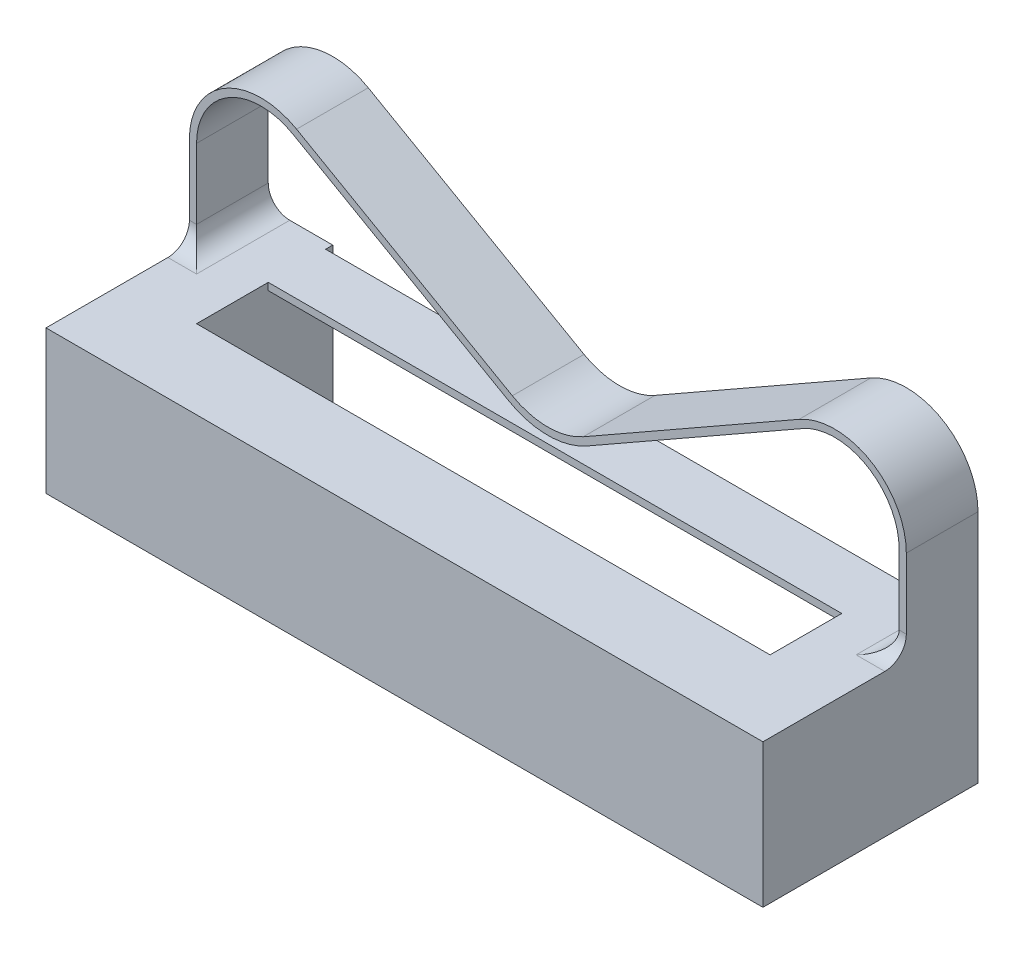
from build123d import *

# Parameters (mm, degrees)
SKIZZE1_W                         = 100
SKIZZE1_H                         = 20
AUFSATZ_LINEAR_AUSTRAGEN1_DEPTH   = 50
SKIZZE3_W                         = 80
SKIZZE3_H                         = 10
SCHNITT_LINEAR_AUSTRAGEN1_DEPTH   = 21
SKIZZE4_W                         = 80
SKIZZE4_H                         = 18
SCHNITT_LINEAR_AUSTRAGEN2_DEPTH   = 19
LINEAR_AUSTRAGEN_D_NN1_DEPTH      = 5
LINEAR_AUSTRAGEN_D_NN1_DEPTH_BACK = 5
SKIZZE5_W                         = 100
SKIZZE5_H                         = 20
SCHNITT_LINEAR_AUSTRAGEN3_DEPTH   = 20
VERRUNDUNG1_R                     = 3


with BuildPart() as part:
    # Skizze1 → Aufsatz-Linear austragen1 (new body)
    with BuildSketch(Plane.XY):
        with Locations((50, 10)):
            Rectangle(SKIZZE1_W, SKIZZE1_H)
    extrude(amount=AUFSATZ_LINEAR_AUSTRAGEN1_DEPTH)

    # Skizze3 → Schnitt-Linear austragen1 (cut, through all)
    with BuildSketch(Plane.XZ):
        with Locations((50, 34)):
            Rectangle(SKIZZE3_W, SKIZZE3_H)
        with Locations((50, 16)):
            Rectangle(SKIZZE3_W, SKIZZE3_H)
    extrude(amount=-SCHNITT_LINEAR_AUSTRAGEN1_DEPTH, mode=Mode.SUBTRACT)

    # Skizze4 → Schnitt-Linear austragen2 (cut)
    with BuildSketch(Plane.XZ):
        with Locations((50, 25)):
            Rectangle(SKIZZE4_W, SKIZZE4_H)
    extrude(amount=-SCHNITT_LINEAR_AUSTRAGEN2_DEPTH, mode=Mode.SUBTRACT)

    # Skizze2 → Linear-Austragen-Dünn1 (add, two sides)
    with BuildSketch(Plane.XY.offset(25)) as linear_austragen_d_nn1_sk:
        with BuildLine():
            Line((0, 20), (0, 32.789569947))
            ThreePointArc((0, 32.789569947), (4.976072473, 41.435965277), (14.95203044, 41.477342649))
            Line((14.95203044, 41.477342649), (45.04796956, 24.322657351))
            ThreePointArc((45.04796956, 24.322657351), (50, 23.010430053), (54.95203044, 24.322657351))
            Line((54.95203044, 24.322657351), (85.04796956, 41.477342649))
            ThreePointArc((85.04796956, 41.477342649), (95.023927527, 41.435965277), (100, 32.789569947))
            Line((100, 32.789569947), (100, 20))
            Line((100, 20), (99, 20))
            Line((99, 20), (99, 32.789569947))
            ThreePointArc((99, 32.789569947), (94.521534775, 40.571325744), (85.543172604, 40.608565379))
            Line((85.543172604, 40.608565379), (55.447233484, 23.453880081))
            ThreePointArc((55.447233484, 23.453880081), (50, 22.010430053), (44.552766516, 23.453880081))
            Line((44.552766516, 23.453880081), (14.456827396, 40.608565379))
            ThreePointArc((14.456827396, 40.608565379), (5.478465225, 40.571325744), (1, 32.789569947))
            Line((1, 32.789569947), (1, 20))
            Line((1, 20), (0, 20))
        make_face()
    extrude(amount=LINEAR_AUSTRAGEN_D_NN1_DEPTH)
    extrude(linear_austragen_d_nn1_sk.sketch, amount=-LINEAR_AUSTRAGEN_D_NN1_DEPTH_BACK)

    # Skizze5 → Schnitt-Linear austragen3 (cut)
    with BuildSketch(Plane(origin=(0, 0, 0), x_dir=(-1, 0, 0), z_dir=(0, 0, -1))):
        with Locations((-50, 10)):
            Rectangle(SKIZZE5_W, SKIZZE5_H)
    extrude(amount=-SCHNITT_LINEAR_AUSTRAGEN3_DEPTH, mode=Mode.SUBTRACT)

    # Verrundung1
    verrundung1_edges = [part.edges().sort_by_distance(p)[0] for p in [
        (99.5, 20, 30),
        (99, 20, 25),
        (1, 20, 25),
        (0.5, 20, 30),
    ]]
    fillet(verrundung1_edges, radius=VERRUNDUNG1_R)


solid = part.part
